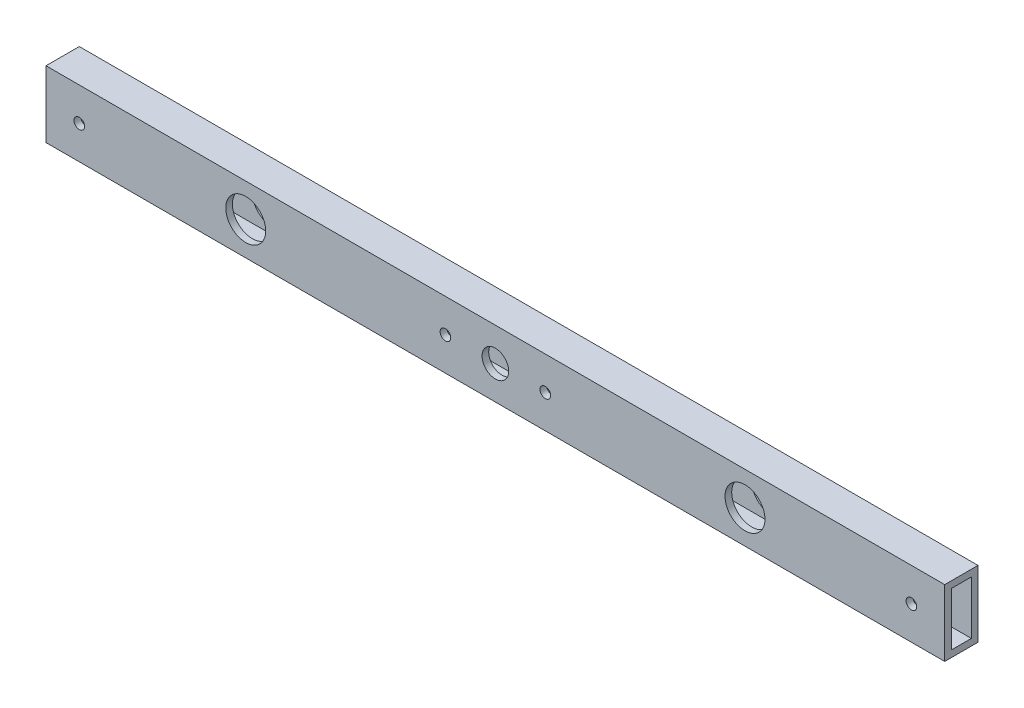
from build123d import *

# Parameters (mm, degrees)
SKETCH_15_W         = 10
SKETCH_15_H         = 20
SKETCH_15_W_2       = 6
SKETCH_15_H_2       = 16
F_20X10X2_2_DEPTH   = 270
SKETCH_12_R         = 1.6
CUT_EXTRUDE_1_DEPTH = 271.370116692
SKETCH_16_R         = 6
CUT_EXTRUDE_2_DEPTH = 271.370116692
SKETCH_17_R         = 4
CUT_EXTRUDE_3_DEPTH = 18
SKETCH_18_R         = 1.6
CUT_EXTRUDE_4_DEPTH = 10


with BuildPart() as part:
    # 草图15 → 铝方管 20X10X2(2) (new body)
    with BuildSketch(Plane(origin=(0, 0, 0), x_dir=(0, 0, -1), z_dir=(1, 0, 0))):
        Rectangle(SKETCH_15_W, SKETCH_15_H)
        Rectangle(SKETCH_15_W_2, SKETCH_15_H_2, mode=Mode.SUBTRACT)
    extrude(amount=F_20X10X2_2_DEPTH)

    # 草图12 → 切除-拉伸1 (cut, through all)
    with BuildSketch(Plane.XY.offset(5)):
        with Locations((10, 0)):
            Circle(SKETCH_12_R)
        with Locations(Location((260, 0, 0), (0, 0, 180))):
            Circle(SKETCH_12_R)
    extrude(amount=-CUT_EXTRUDE_1_DEPTH, mode=Mode.SUBTRACT)

    # 草图16 → 切除-拉伸2 (cut, through all)
    with BuildSketch(Plane.XY.offset(5)):
        with Locations((60, 0)):
            Circle(SKETCH_16_R)
        with Locations(Location((210, 0, 0), (0, 0, 180))):
            Circle(SKETCH_16_R)
    extrude(amount=-CUT_EXTRUDE_2_DEPTH, mode=Mode.SUBTRACT)

    # 草图17 → 切除-拉伸3 (cut)
    with BuildSketch(Plane.XY.offset(5)):
        with Locations((135, 0)):
            Circle(SKETCH_17_R)
    extrude(amount=-CUT_EXTRUDE_3_DEPTH, mode=Mode.SUBTRACT)

    # 草图18 → 切除-拉伸4 (cut)
    with BuildSketch(Plane.XY.offset(5)):
        with Locations((120, 0)):
            Circle(SKETCH_18_R)
        with Locations((150, 0)):
            Circle(SKETCH_18_R)
    extrude(amount=-CUT_EXTRUDE_4_DEPTH, mode=Mode.SUBTRACT)


solid = part.part
